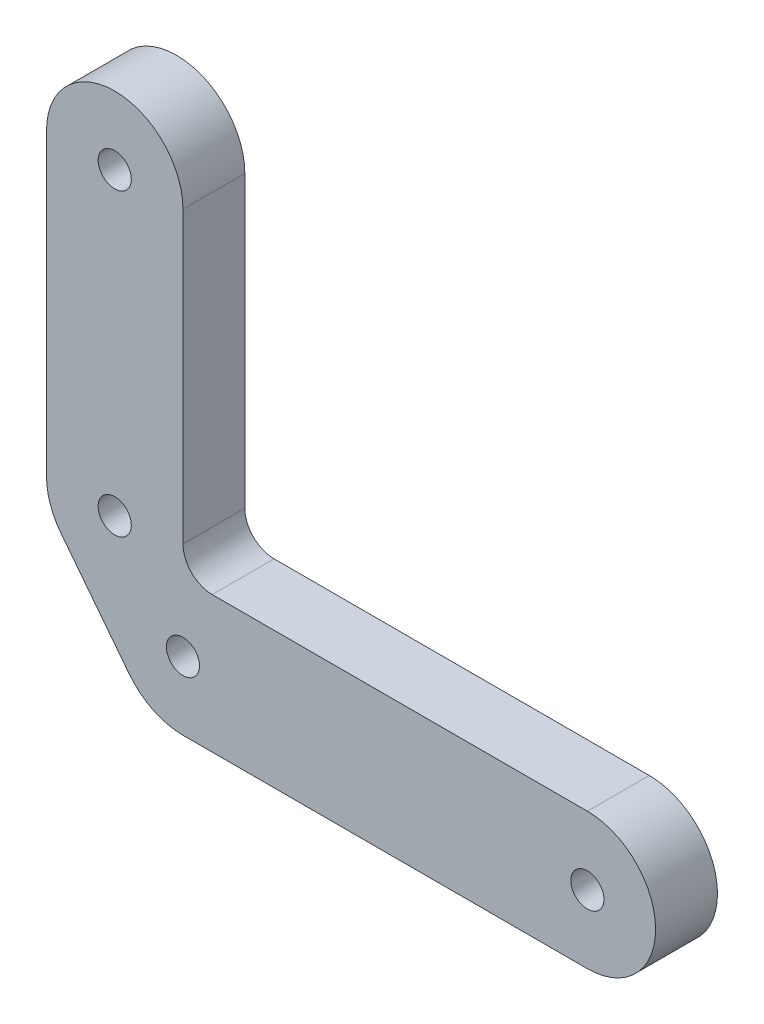
from build123d import *

# Parameters (mm, degrees)
BOSS_EXTRUDE1_DEPTH  = 6.35
FILLET1_R            = 3
M3_CLEARANCE_HOLE1_D = 3.4


with BuildPart() as part:
    # Sketch2 → Boss-Extrude1 (new body)
    with BuildSketch(Plane.XY):
        with BuildLine():
            Line((-14, 39.75), (-14, 9))
            ThreePointArc((-14, 9), (-13.621112393, 6.728245023), (-12.525465522, 4.702415705))
            Line((-12.525465522, 4.702415705), (-5.525465522, -4.297584295))
            ThreePointArc((-5.525465522, -4.297584295), (-3.075460123, -6.288206822), (0, -7))
            Line((0, -7), (41.5, -7))
            ThreePointArc((41.5, -7), (48.5, 0), (41.5, 7))
            Line((41.5, 7), (0, 7))
            Line((0, 7), (0, 39.75))
            ThreePointArc((0, 39.75), (-7, 46.75), (-14, 39.75))
        make_face()
    extrude(amount=BOSS_EXTRUDE1_DEPTH)

    # Fillet1
    fillet1_edges = [part.edges().sort_by_distance(p)[0] for p in [
        (0, 7, 3.175),
    ]]
    fillet(fillet1_edges, radius=FILLET1_R)

    # M3 Clearance Hole1 (through all)
    with Locations(Plane.XY.offset(6.35)):
        with Locations((-7, 39.75), (-7, 9), (0, 0), (41.5, 0)):
            Hole(M3_CLEARANCE_HOLE1_D / 2)


solid = part.part
